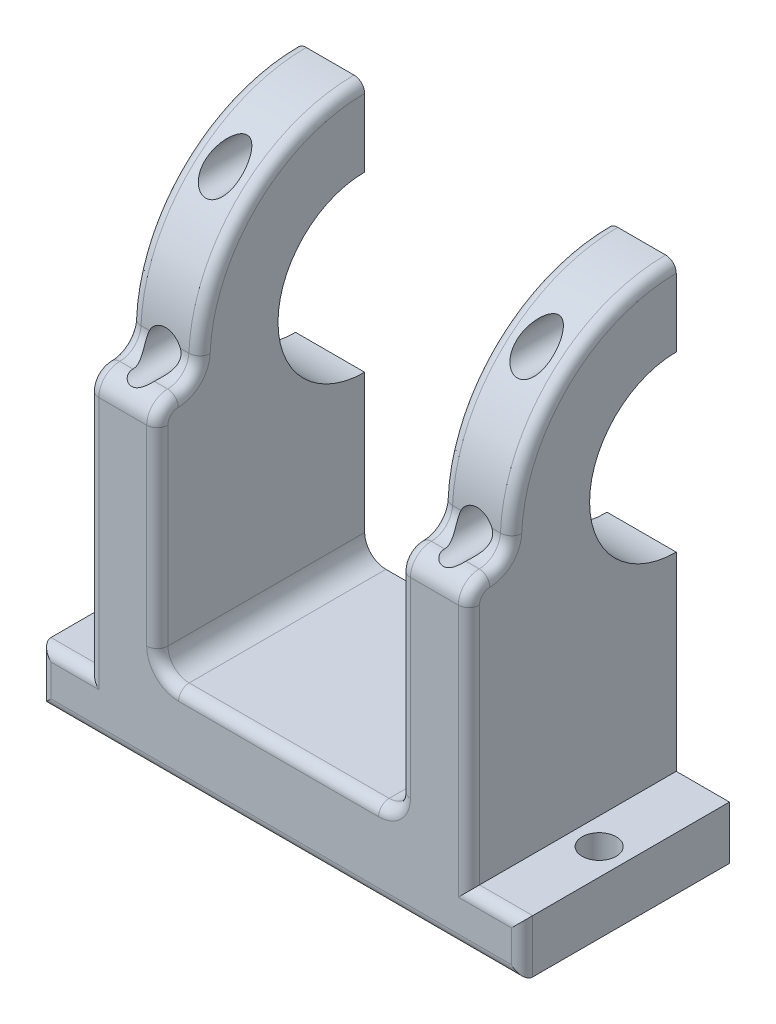
from build123d import *

# Parameters (mm, degrees)
SKETCH3_R               = 15.55
SKETCH3_R_2             = 8.15
BOSS_EXTRUDE4_DEPTH     = 6.5
SKETCH2_R               = 15.55
SKETCH2_R_2             = 8.15
BOSS_EXTRUDE5_DEPTH     = 6.5
CUT_EXTRUDE1_DEPTH      = 35.8
SKETCH5_R               = 1.6
CUT_EXTRUDE2_DEPTH      = 43.014818814
BOSS_EXTRUDE6_DEPTH     = 6.5
SKETCH9_W               = 6.5
SKETCH9_H               = 21.954006421
BOSS_EXTRUDE7_DEPTH     = 4
BOSS_EXTRUDE8_DEPTH     = 6.5
FILLET1_R               = 2
FILLET5_R               = 2
CUT_EXTRUDE3_DEPTH      = 47.905543459
BOSS_EXTRUDE10_START    = -6.5
SKETCH13_W              = 19.5
SKETCH13_H              = 7.8
BOSS_EXTRUDE10_DEPTH    = 35.8
FILLET3_R               = 2
SKETCH14_W              = 19.5
SKETCH14_H              = 5
BOSS_EXTRUDE11_DEPTH    = 5
CUT_EXTRUDE4_DEPTH      = 62.410850086
SKETCH20_W              = 19.5
SKETCH20_H              = 5
BOSS_EXTRUDE13_DEPTH    = 4.5
SKETCH21_R              = 1.6
CUT_EXTRUDE7_DEPTH      = 62.410850086
FILLET6_R               = 1
SKETCH22_R              = 2.35
CUT_EXTRUDE8_DEPTH      = 10
SKETCH23_R              = 1.6
CUT_EXTRUDE9_DEPTH      = 54.54433838
CUT_EXTRUDE9_DEPTH_BACK = 54.54433838


with BuildPart() as part:
    # Sketch3 → Boss-Extrude4 (new body)
    with BuildSketch(Plane(origin=(0, 0, 0), x_dir=(0, 0, -1), z_dir=(1, 0, 0))):
        with Locations(Location((0, 0, 0), (0, 0, 180))):
            Circle(SKETCH3_R)
        with Locations(Location((0, 0, 0), (0, 0, 180))):
            Circle(SKETCH3_R_2, mode=Mode.SUBTRACT)
    extrude(amount=BOSS_EXTRUDE4_DEPTH)


with BuildPart() as body_2:
    # Sketch2 → Boss-Extrude5 (new body)
    with BuildSketch(Plane(origin=(35.8, 0, 0), x_dir=(0, 0, -1), z_dir=(1, 0, 0))):
        Circle(SKETCH2_R)
        Circle(SKETCH2_R_2, mode=Mode.SUBTRACT)
    extrude(amount=-BOSS_EXTRUDE5_DEPTH)


with BuildPart() as cut_extrude1_tool:
    # Sketch4 → Cut-Extrude1 (new body)
    with BuildSketch(Plane(origin=(0, 0, 0), x_dir=(0, 0, -1), z_dir=(1, 0, 0))):
        with BuildLine():
            Line((0, 15.55), (0, -15.55))
            ThreePointArc((0, -15.55), (15.55, 0), (0, 15.55))
        make_face()
    extrude(amount=CUT_EXTRUDE1_DEPTH)


with BuildPart() as part_1:
    add(part.part)

    # Cut-Extrude1: cut by cut_extrude1_tool
    add(cut_extrude1_tool.part, mode=Mode.SUBTRACT)


with BuildPart() as body_2_1:
    add(body_2.part)

    # Cut-Extrude1: cut by cut_extrude1_tool
    add(cut_extrude1_tool.part, mode=Mode.SUBTRACT)


with BuildPart() as cut_extrude2_tool:
    # Sketch5 → Cut-Extrude2 (new, through all)
    with BuildSketch(Plane(origin=(0, 0, 0), x_dir=(-1, 0, 0), z_dir=(0, 0, -1))):
        with Locations((-32.55, 11.85)):
            Circle(SKETCH5_R)
        with Locations((-3.25, 11.85)):
            Circle(SKETCH5_R)
    extrude(amount=-CUT_EXTRUDE2_DEPTH)


with BuildPart() as part_2:
    add(part_1.part)

    # Cut-Extrude2: cut by cut_extrude2_tool
    add(cut_extrude2_tool.part, mode=Mode.SUBTRACT)

    # Sketch11 → Boss-Extrude8 (add)
    with BuildSketch(Plane.ZY):
        with BuildLine():
            ThreePointArc((15.5, -1.245993579), (10.545788255, -11.427547859), (0, -15.55))
            Line((0, -15.55), (0, -23.2))
            Line((0, -23.2), (19.5, -23.2))
            Line((19.5, -23.2), (19.5, -1.245993579))
            Line((19.5, -1.245993579), (15.5, -1.245993579))
        make_face()
    extrude(amount=-BOSS_EXTRUDE8_DEPTH)

    # Fillet5
    fillet5_edges = [part_2.edges().sort_by_distance(p)[0] for p in [
        (3.25, -1.245993579, 15.5),
    ]]
    fillet(fillet5_edges, radius=FILLET5_R)


with BuildPart() as body_2_2:
    add(body_2_1.part)

    # Cut-Extrude2: cut by cut_extrude2_tool
    add(cut_extrude2_tool.part, mode=Mode.SUBTRACT)

    # Sketch8 → Boss-Extrude6 (add)
    with BuildSketch(Plane.ZY.offset(-29.3)):
        with BuildLine():
            ThreePointArc((15.5, -11.330931118), (8.691551143, -17.120074145), (0, -19.2))
            Line((0, -19.2), (0, -23.2))
            Line((0, -23.2), (15.5, -23.2))
            Line((15.5, -23.2), (15.5, -11.330931118))
        make_face()
        with BuildLine():
            ThreePointArc((15.5, -1.245993579), (10.545788255, -11.427547859), (0, -15.55))
            Line((0, -15.55), (0, -19.2))
            ThreePointArc((0, -19.2), (8.691551143, -17.120074145), (15.5, -11.330931118))
            Line((15.5, -11.330931118), (15.5, -1.245993579))
        make_face()
    extrude(amount=-BOSS_EXTRUDE6_DEPTH)

    # Sketch9 → Boss-Extrude7 (add)
    with BuildSketch(Plane(origin=(0, 0, 15.5), x_dir=(-1, 0, 0), z_dir=(0, 0, -1))):
        with Locations((-32.55, -12.22299679)):
            Rectangle(SKETCH9_W, SKETCH9_H)
    extrude(amount=-BOSS_EXTRUDE7_DEPTH)

    # Fillet1
    fillet1_edges = [body_2_2.edges().sort_by_distance(p)[0] for p in [
        (32.55, -1.245993579, 15.5),
    ]]
    fillet(fillet1_edges, radius=FILLET1_R)


with BuildPart() as cut_extrude3_tool:
    # Sketch10 → Cut-Extrude3 (new, through all)
    with BuildSketch(Plane.ZY.offset(-35.8)):
        with BuildLine():
            Line((19.5, -1.245993579), (19.5, -3.212198374))
            ThreePointArc((19.5, -3.212198374), (18.924111949, -1.82188163), (17.533795206, -1.245993579))
            Line((17.533795206, -1.245993579), (19.5, -1.245993579))
        make_face()
    extrude(amount=CUT_EXTRUDE3_DEPTH)


with BuildPart() as part_3:
    add(part_2.part)

    # Cut-Extrude3: cut by cut_extrude3_tool
    add(cut_extrude3_tool.part, mode=Mode.SUBTRACT)



with BuildPart() as body_2_3:
    add(body_2_2.part)

    # Cut-Extrude3: cut by cut_extrude3_tool
    add(cut_extrude3_tool.part, mode=Mode.SUBTRACT)


with BuildPart() as part_4:
    add(part_3.part)

    add(body_2_3.part)  # Boss-Extrude10 merges body 2
    # Sketch13 → Boss-Extrude10 (add)
    with BuildSketch(Plane.ZY.offset(-29.3).offset(BOSS_EXTRUDE10_START)):
        with Locations((9.75, -27.1)):
            Rectangle(SKETCH13_W, SKETCH13_H)
    extrude(amount=BOSS_EXTRUDE10_DEPTH)

    # Fillet3
    fillet3_edges = [part_4.edges().sort_by_distance(p)[0] for p in [
        (6.5, -23.2, 9.75),
        (29.3, -23.2, 9.75),
    ]]
    fillet(fillet3_edges, radius=FILLET3_R)

    # Sketch14 → Boss-Extrude11 (add)
    with BuildSketch(Plane.ZY.offset(-35.8)):
        with Locations((9.75, -28.5)):
            Rectangle(SKETCH14_W, SKETCH14_H)
    extrude(amount=-BOSS_EXTRUDE11_DEPTH)

    # Sketch15 → Cut-Extrude4 (cut, through all)
    with BuildSketch(Plane(origin=(0, -26, 0), x_dir=(1, 0, 0), z_dir=(0, 1, 0))):
        with BuildLine():
            ThreePointArc((39.9, -9.75), (39.43137085, -8.61862915), (38.3, -8.15))
            Line((38.3, -8.15), (38.3, -11.35))
            ThreePointArc((38.3, -11.35), (39.43137085, -10.88137085), (39.9, -9.75))
        make_face()
        with BuildLine():
            Line((38.3, -11.35), (38.3, -8.15))
            ThreePointArc((38.3, -8.15), (36.7, -9.75), (38.3, -11.35))
        make_face()
    extrude(amount=-CUT_EXTRUDE4_DEPTH, mode=Mode.SUBTRACT)

    # Sketch20 → Boss-Extrude13 (add)
    with BuildSketch(Plane.ZY):
        with Locations((9.75, -28.5)):
            Rectangle(SKETCH20_W, SKETCH20_H)
    extrude(amount=BOSS_EXTRUDE13_DEPTH)

    # Sketch21 → Cut-Extrude7 (cut, through all)
    with BuildSketch(Plane(origin=(0, -26, 0), x_dir=(1, 0, 0), z_dir=(0, 1, 0))):
        with Locations(Location((-2.25, -9.75, 0), (0, 0, 270))):
            Circle(SKETCH21_R)
    extrude(amount=-CUT_EXTRUDE7_DEPTH, mode=Mode.SUBTRACT)

    # Fillet6
    fillet6_edges = [part_4.edges().sort_by_distance(p)[0] for p in [
        (0, 11.229228387, 10.756715569),
        (0, -1.82188163, 18.924111949),
        (29.3, -12.206099187, 19.5),
        (17.9, -23.2, 19.5),
        (6.5, -12.206099187, 19.5),
        (28.714213562, -22.614213562, 19.5),
        (7.085786438, -22.614213562, 19.5),
        (40.8, -28.5, 19.5),
        (38.3, -26, 19.5),
        (-2.25, -26, 19.5),
        (-4.5, -28.5, 19.5),
        (35.8, 11.229228387, 10.756715569),
        (29.3, 11.229228387, 10.756715569),
        (29.3, -0.690267327, 16.150294811),
        (35.8, -0.690267327, 16.150294811),
        (35.8, -14.606099187, 19.5),
        (35.8, -1.82188163, 18.924111949),
        (29.3, -1.82188163, 18.924111949),
        (0, -14.606099187, 19.5),
        (18.15, -31, 19.5),
        (6.5, -0.690267327, 16.150294811),
        (6.5, -1.82188163, 18.924111949),
        (6.5, 11.229228387, 10.756715569),
        (0, -0.690267327, 16.150294811),
    ]]
    fillet(fillet6_edges, radius=FILLET6_R)

    # Sketch22 → Cut-Extrude8 (cut)
    with BuildSketch(Plane(origin=(0, 0, 0), x_dir=(-1, 0, 0), z_dir=(0, 0, -1))):
        with Locations((-8.5, -27.1)):
            Circle(SKETCH22_R)
        with Locations((-27.3, -27.1)):
            Circle(SKETCH22_R)
    extrude(amount=-CUT_EXTRUDE8_DEPTH, mode=Mode.SUBTRACT)

    # Sketch23 → Cut-Extrude9 (cut, two sides)
    with BuildSketch(Plane.XY.offset(15.535641906)) as cut_extrude9_sk:
        with Locations((3.25, 0)):
            Circle(SKETCH23_R)
        with Locations((32.55, 0)):
            Circle(SKETCH23_R)
    extrude(amount=CUT_EXTRUDE9_DEPTH, mode=Mode.SUBTRACT)
    extrude(cut_extrude9_sk.sketch, amount=-CUT_EXTRUDE9_DEPTH_BACK, mode=Mode.SUBTRACT)


solid = part_4.part
